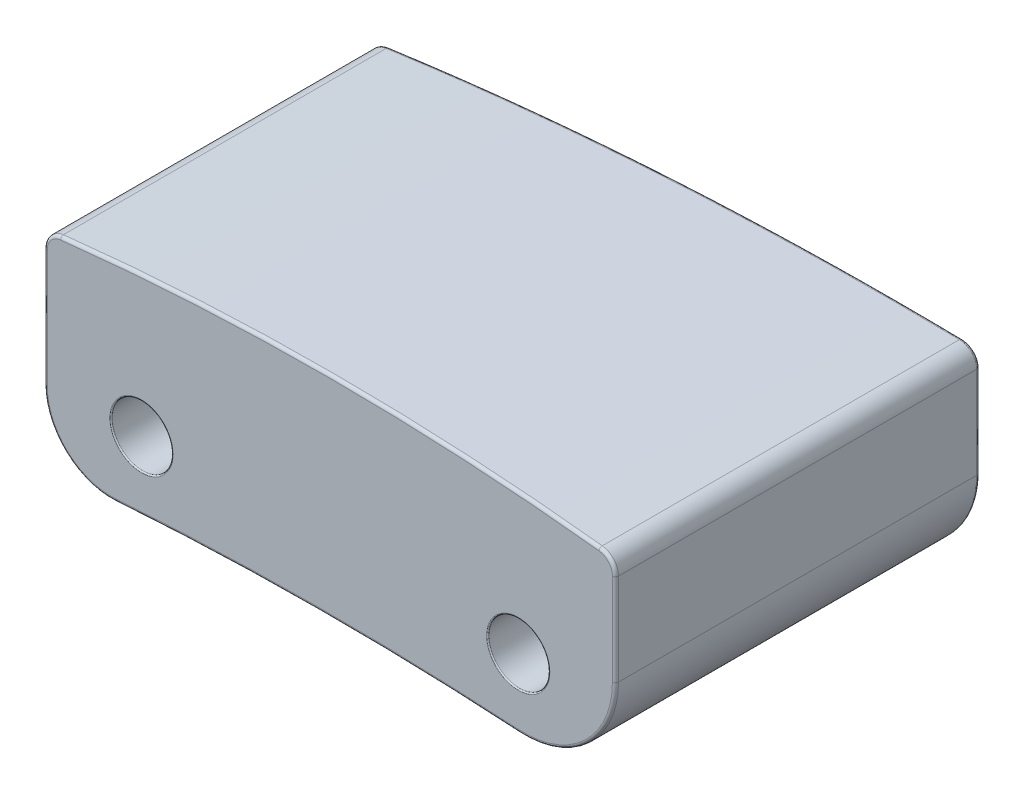
from build123d import *

# Parameters (mm, degrees)
SKETCH1_W               = 9.4
SKETCH1_H               = 3.7
BOSS_EXTRUDE1_DEPTH     = 3
CUT_EXTRUDE1_DEPTH      = 15.6
FILLET1_R               = 1.1
FILLET6_R               = 1.5
FILLET2_R               = 0.3
SKETCH3_R               = 0.5
CUT_EXTRUDE2_DEPTH      = 3
CUT_EXTRUDE3_DEPTH      = 5
FILLET5_R               = 0.05
CUT_EXTRUDE5_REACH      = 17.868
CUT_EXTRUDE5_END_RADIUS = 50.4
CUT_EXTRUDE5_START      = -10
SKETCH5_R               = 0.4
FILLET7_R               = 0.05
FILLET8_R               = 0.02


with BuildPart() as part:
    # Sketch1 → Boss-Extrude1 (new, symmetric)
    with BuildSketch(Plane.XY):
        Rectangle(SKETCH1_W, SKETCH1_H)
    extrude(amount=BOSS_EXTRUDE1_DEPTH, both=True)

    # Sketch2 → Cut-Extrude1 (cut)
    with BuildSketch(Plane.XY.offset(3)):
        with BuildLine():
            Line((-4.7, 1.55), (-7.120690005, 4.011417256))
            Line((-7.120690005, 4.011417256), (5.535860742, 3.886722174))
            Line((5.535860742, 3.886722174), (4.7, 1.55))
            ThreePointArc((4.7, 1.55), (0, 1.827084699), (-4.7, 1.55))
        make_face()
        with BuildLine():
            Line((4.7, -1.85), (0.350623614, -3.782025322))
            Line((0.350623614, -3.782025322), (-4.7, -1.85))
            ThreePointArc((-4.7, -1.85), (0, -1.628609864), (4.7, -1.85))
        make_face()
    extrude(amount=-CUT_EXTRUDE1_DEPTH, mode=Mode.SUBTRACT)

    # Fillet1
    fillet1_edges = [part.edges().sort_by_distance(p)[0] for p in [
        (-4.7, -1.85, 0),
    ]]
    fillet(fillet1_edges, radius=FILLET1_R)

    # Fillet6
    fillet6_edges = [part.edges().sort_by_distance(p)[0] for p in [
        (4.7, -1.85, 0),
    ]]
    fillet(fillet6_edges, radius=FILLET6_R)

    # Fillet2
    fillet2_edges = [part.edges().sort_by_distance(p)[0] for p in [
        (4.7, 1.55, 0),
        (-4.7, 1.55, 0),
    ]]
    fillet(fillet2_edges, radius=FILLET2_R)

    # Sketch3 → Cut-Extrude2 (cut)
    with BuildSketch(Plane.XY.offset(3)):
        with Locations((3.1, -0.6)):
            Circle(SKETCH3_R)
        with Locations((-3.1, -0.6)):
            Circle(SKETCH3_R)
    extrude(amount=-CUT_EXTRUDE2_DEPTH, mode=Mode.SUBTRACT)

    # Sketch4 → Cut-Extrude3 (cut, symmetric)
    with BuildSketch(Plane(origin=(0, 0, 0), x_dir=(1, 0, 0), z_dir=(0, 1, 0))):
        with BuildLine():
            Line((-4.7, 2.4), (-6.612719149, 4.113907535))
            Line((-6.612719149, 4.113907535), (6.420677859, 4.974089961))
            Line((6.420677859, 4.974089961), (4.7, 3))
            ThreePointArc((4.7, 3), (0.004710726, 2.626198627), (-4.7, 2.4))
        make_face()
    extrude(amount=CUT_EXTRUDE3_DEPTH, both=True, mode=Mode.SUBTRACT)

    # Fillet5
    fillet5_edges = [part.edges().sort_by_distance(p)[0] for p in [
        (-4.349918456, -1.460327621, 3),
        (4.7, 0.527189546, -3),
        (4.7, 0.527189546, 3),
        (-0.208312642, -1.629043808, 3),
        (4.22717919, -1.321239633, 3),
        (0, 1.827084699, 3),
        (-4.7, 0.3134624, 3),
        (-4.623578634, 1.482534062, 3),
        (4.623578634, 1.482534062, 3),
        (2.6, -0.6, 0),
        (-4.623553452, 1.482562201, -2.402492735),
        (-4.349757648, -1.460477444, -2.41174073),
        (4.226094878, -1.322257528, -2.955532113),
        (4.623384052, 1.482751333, -2.992708088),
        (-0.206022635, -1.629034318, -2.612896489),
        (0.004177998, 1.827084481, -2.626164624),
        (-4.7, 0.3134624, -2.4),
    ]]
    fillet(fillet5_edges, radius=FILLET5_R)

    # Cut-Extrude5: up to this cylinder (the profile starts inside it)
    cut_extrude5_end = Plane(origin=(0, -51.628609864, 1.5), z_dir=(0, 0, 1)) * Cylinder(CUT_EXTRUDE5_END_RADIUS, 137.536, mode=Mode.PRIVATE)
    # Sketch5 → Cut-Extrude5 (cut, up to the surface)
    with BuildSketch(Plane(origin=(0, 0, 0), x_dir=(1, 0, 0), z_dir=(0, 1, 0)).offset(CUT_EXTRUDE5_START), mode=Mode.PRIVATE) as cut_extrude5_sk1:
        with Locations(Location((-0.7, -1.5, 0), (0, 0, 90))):
            Circle(SKETCH5_R)
    cut_extrude5_tool1 = extrude(cut_extrude5_sk1.sketch, amount=CUT_EXTRUDE5_REACH, mode=Mode.PRIVATE) & cut_extrude5_end
    add(cut_extrude5_tool1.solids().sort_by_distance((-0.7, -10, 1.5))[0], mode=Mode.SUBTRACT)

    # Fillet7
    fillet7_edges = [part.edges().sort_by_distance(p)[0] for p in [
        (-0.700029875, -1.633510522, 1.899999999),
    ]]
    fillet(fillet7_edges, radius=FILLET7_R)

    # Fillet8
    fillet8_edges = [part.edges().sort_by_distance(p)[0] for p in [
        (2.6, -0.6, 3),
        (-3.6, -0.6, 3),
    ]]
    fillet(fillet8_edges, radius=FILLET8_R)


solid = part.part
